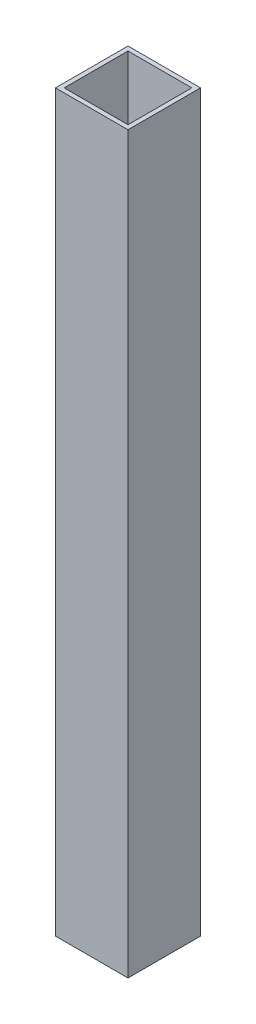
from build123d import *

# Parameters (mm, degrees)
CROQUIS1_W              = 50
CROQUIS1_H              = 50
CROQUIS1_W_2            = 44
CROQUIS1_H_2            = 44
SALIENTE_EXTRUIR1_DEPTH = 506.49


with BuildPart() as part:
    # Croquis1 → Saliente-Extruir1 (new body)
    with BuildSketch(Plane(origin=(0, 0, 0), x_dir=(1, 0, 0), z_dir=(0, 1, 0))):
        with Locations((-5.851407977, 10)):
            Rectangle(CROQUIS1_W, CROQUIS1_H)
        with Locations((-5.851407977, 10)):
            Rectangle(CROQUIS1_W_2, CROQUIS1_H_2, mode=Mode.SUBTRACT)
    extrude(amount=SALIENTE_EXTRUIR1_DEPTH)


solid = part.part
